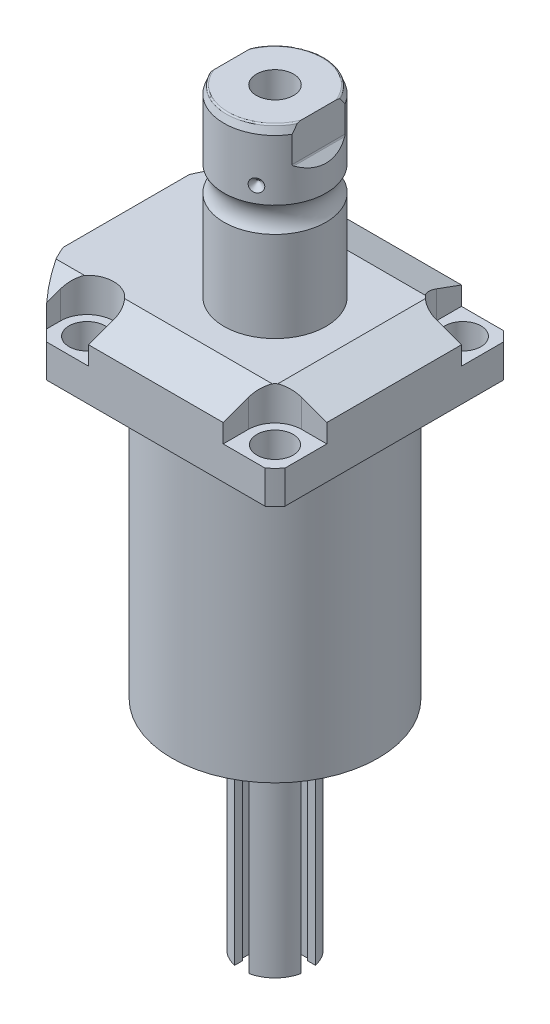
from build123d import *

# Parameters (mm, degrees)
SKETCH1_W                   = 88.9
SKETCH1_H                   = 99.9998
EXTRUDE1_DEPTH              = 129.794
SKETCH2_OUTSIDE_W           = 139.282
SKETCH2_OUTSIDE_H           = 128.182
SKETCH2_OUTSIDE_R           = 60.325
CUT_EXTRUDE1_DEPTH          = 130.794
SKETCH3_W                   = 38.1
SKETCH3_H                   = 104.775
FILLET1_R                   = 0.381
CUT_EXTRUDE2_DEPTH          = 12.7
CUT_EXTRUDE9_START          = -56.5498
CUT_EXTRUDE9_DEPTH          = 101.9998
CUT_EXTRUDE7_DEPTH          = 45.45
CUT_EXTRUDE7_DEPTH_BACK     = 45.45
SKETCH10_R                  = 1.1811
SKETCH11_R                  = 1.1811
CUT_EXTRUDE8_DEPTH          = 53.34
SKETCH17_W                  = 6.7437
SKETCH17_H                  = 12.319
HOLE1_AT_2_COUNT            = 2
HOLE1_AT_2_PITCH            = 70.104
HOLE1_AT_3_COUNT            = 2
HOLE1_AT_3_PITCH            = 99.142027577
HOLE1_AT_4_COUNT            = 2
HOLE1_AT_4_PITCH            = 70.104
CHAMFER1_SIZE               = 0.635
FILLET2_R                   = 0.635
CIRPATTERN1_COUNT           = 3
SKETCH24_R                  = 1.7272
CUT_EXTRUDE10_DEPTH         = 2.54
SKETCH25_R                  = 2.7051
EXTRUDE2_DEPTH              = 2.9464
CUT_EXTRUDE11_DEPTH         = 6.477
SKETCH32_W                  = 6.985
SKETCH32_H                  = 70.612
CUT_EXTRUDE12_DEPTH         = 3.302
CUT_EXTRUDE13_DEPTH         = 2.032
CIRPATTERN2_COUNT           = 2
CIRPATTERN2_ANGLE           = 90
CIRPATTERN2_COPY_1_DEPTH    = 6.477
CIRPATTERN2_COPY_2_SKETCH_W = 6.985
CIRPATTERN2_COPY_2_SKETCH_H = 70.612
CIRPATTERN2_COPY_2_DEPTH    = 3.302


with BuildPart() as part:
    # Sketch1 → Extrude1 (new body)
    with BuildSketch(Plane.ZX):
        with Locations((0, -5.5499)):
            Rectangle(SKETCH1_W, SKETCH1_H)
    extrude(amount=EXTRUDE1_DEPTH)

    # Sketch2 outside → Cut-Extrude1 (cut, through all)
    with BuildSketch(Plane.XZ):
        with Locations((-5.55, 0)):
            Rectangle(SKETCH2_OUTSIDE_W, SKETCH2_OUTSIDE_H)
        Circle(SKETCH2_OUTSIDE_R, mode=Mode.SUBTRACT)
    extrude(amount=-CUT_EXTRUDE1_DEPTH, mode=Mode.SUBTRACT)

    # Sketch3 → Cut-Revolve1 (revolve, cut)
    with BuildSketch(Plane(origin=(0, 0, 0), x_dir=(0, 0, 1), z_dir=(1, 0, 0))):
        with Locations((57.5437, -52.3875)):
            Rectangle(SKETCH3_W, SKETCH3_H)
    revolve(axis=Axis((0, 93.345, 0), (0, -1, 0)), mode=Mode.SUBTRACT)

    # Fillet1
    fillet1_edges = [part.edges().sort_by_distance(p)[0] for p in [
        (0, 104.775, -38.4937),
    ]]
    fillet(fillet1_edges, radius=FILLET1_R)

    # Sketch4 → Cut-Extrude2 (cut)
    with BuildSketch(Plane(origin=(0, 129.794, 0), x_dir=(-1, 0, 0), z_dir=(0, 1, 0))):
        with BuildLine():
            Line((-25.1206, -44.45), (-25.1206, -35.052))
            ThreePointArc((-25.1206, -35.052), (-28.029439713, -28.029439713), (-35.052, -25.1206))
            Line((-35.052, -25.1206), (-44.45, -25.1206))
            Line((-44.45, -25.1206), (-44.45, -44.45))
            Line((-44.45, -44.45), (-25.1206, -44.45))
        make_face()
        with BuildLine():
            Line((44.9834, -44.45), (25.1206, -44.45))
            Line((25.1206, -44.45), (25.1206, -35.052))
            ThreePointArc((25.1206, -35.052), (35.052, -25.1206), (44.9834, -35.052))
            Line((44.9834, -35.052), (44.9834, -44.45))
        make_face()
        with BuildLine():
            Line((25.1206, 44.45), (25.1206, 35.052))
            ThreePointArc((25.1206, 35.052), (35.052, 25.1206), (44.9834, 35.052))
            Line((44.9834, 35.052), (44.9834, 44.45))
            Line((44.9834, 44.45), (25.1206, 44.45))
        make_face()
        with BuildLine():
            Line((-35.052, 25.1206), (-44.45, 25.1206))
            Line((-44.45, 25.1206), (-44.45, 44.45))
            Line((-44.45, 44.45), (-25.1206, 44.45))
            Line((-25.1206, 44.45), (-25.1206, 35.052))
            ThreePointArc((-25.1206, 35.052), (-28.029439713, 28.029439713), (-35.052, 25.1206))
        make_face()
    extrude(amount=-CUT_EXTRUDE2_DEPTH, mode=Mode.SUBTRACT)

    # Sketch5 → Cut-Extrude9 (cut)
    with BuildSketch(Plane(origin=(0, 0, 0), x_dir=(0, 0, -1), z_dir=(1, 0, 0)).offset(CUT_EXTRUDE9_START)):
        Polygon((-28.575, 129.794), (-44.45, 124.015972531), (-44.45, 129.794), align=None)
    cut_extrude9 = extrude(amount=CUT_EXTRUDE9_DEPTH, mode=Mode.SUBTRACT)

    # Mirror1: Cut-Extrude9 across plane
    add(cut_extrude9.mirror(Plane.XY), mode=Mode.SUBTRACT)

    # Sketch9 → Cut-Extrude7 (cut, two sides)
    with BuildSketch(Plane.XY) as cut_extrude7_sk:
        Polygon((28.575, 129.794), (44.45, 124.015972531), (44.45, 129.794), align=None)
    extrude(amount=CUT_EXTRUDE7_DEPTH, mode=Mode.SUBTRACT)
    extrude(cut_extrude7_sk.sketch, amount=-CUT_EXTRUDE7_DEPTH_BACK, mode=Mode.SUBTRACT)

    # Sketch20 → Cut-Revolve4 (revolve, cut)
    with BuildSketch(Plane(origin=(-41.402, 88.9, -18.1102), x_dir=(0, 1, 0), z_dir=(1, 0, 0)), mode=Mode.PRIVATE) as cut_revolve4_sk:
        Polygon((15.875, 41.9227), (17.3228, 41.9227), (17.3228, 39.4716), (18.3388, 39.4716), (18.3388, 37.465), (29.3116, 37.465), (29.3116, 36.2204), (15.875, 36.2204), align=None)
    cut_revolve4 = revolve(cut_revolve4_sk.sketch.rotate(Axis((-41.402, 81.620304954, 18.1102), (0, 1, 0)), 180), axis=Axis((-41.402, 81.620304954, 18.1102), (0, 1, 0)), mode=Mode.SUBTRACT)  # turned: the seam where the file's is

    # Mirror10: Cut-Revolve4 across plane
    add(cut_revolve4.mirror(Plane.XY), mode=Mode.SUBTRACT)

    # S2D0007 → Cut-Revolve2 (revolve, cut)
    with BuildSketch(Plane(origin=(-55.5498, 101.9048, 12.9794), x_dir=(0, 1, 0), z_dir=(0, 0, 1)), mode=Mode.PRIVATE) as cut_revolve2_sk:
        Polygon((15.875, 0), (26.3525, 0), (26.3525, -0.254), (22.0599, -0.254), (21.517306865, -2.8067), (20.8534, -3.470606865), (20.8534, -14.224), (15.875, -14.224), align=None)
    revolve(cut_revolve2_sk.sketch.rotate(Axis((944.4502, 117.7798, 12.9794), (-1, 0, 0)), 90), axis=Axis((944.4502, 117.7798, 12.9794), (-1, 0, 0)), mode=Mode.SUBTRACT)  # turned: the seam where the file's is

    # Sketch13 → Cut-Revolve3 (revolve, cut)
    with BuildSketch(Plane(origin=(-55.5498, 101.9048, -12.9794), x_dir=(0, 1, 0), z_dir=(0, 0, 1)), mode=Mode.PRIVATE) as cut_revolve3_sk:
        Polygon((15.875, 0), (26.3525, 0), (26.3525, -0.254), (22.0599, -0.254), (21.517306865, -2.8067), (20.8534, -3.470606865), (20.8534, -14.224), (15.875, -14.224), align=None)
    revolve(cut_revolve3_sk.sketch.rotate(Axis((944.4502, 117.7798, -12.9794), (-1, 0, 0)), 90), axis=Axis((944.4502, 117.7798, -12.9794), (-1, 0, 0)), mode=Mode.SUBTRACT)  # turned: the seam where the file's is

    # Sketch15 → Revolve3 (revolve)
    with BuildSketch(Plane(origin=(0, 0, 0), x_dir=(0, -1, 0), z_dir=(1, 0, 0)), mode=Mode.PRIVATE) as revolve3_sk:
        with BuildLine():
            Line((-129.794, 0), (-129.794, 19.05))
            Line((-129.794, 19.05), (-163.46630643, 19.05))
            ThreePointArc((-163.46630643, 19.05), (-168.1734, 17.5006), (-172.88049357, 19.05))
            Line((-172.88049357, 19.05), (-195.4276, 19.05))
            Line((-195.4276, 19.05), (-198.3486, 17.986842946))
            Line((-198.3486, 17.986842946), (-198.3486, 0))
            Line((-198.3486, 0), (-129.794, 0))
        make_face()
    revolve(revolve3_sk.sketch.rotate(Axis((0, 197.63613, 0), (0, -1, 0)), 180), axis=Axis((0, 197.63613, 0), (0, -1, 0)))  # turned: the seam where the file's is

    # Sketch16 → Cut-Extrude8 (cut, symmetric)
    with BuildSketch(Plane(origin=(0, 0, 0), x_dir=(0, -1, 0), z_dir=(0, 0, -1))):
        with BuildLine():
            Line((-198.3486, 19.05), (-182.564369265, 19.05))
            Line((-182.564369265, 19.05), (-185.109784633, 16.504584633))
            ThreePointArc((-185.109784633, 16.504584633), (-185.356995225, 16.339403796), (-185.6486, 16.2814))
            Line((-185.6486, 16.2814), (-198.3486, 16.2814))
            Line((-198.3486, 16.2814), (-198.3486, 19.05))
        make_face()
        with BuildLine():
            Line((-198.3486, -19.05), (-198.3486, -16.2814))
            Line((-198.3486, -16.2814), (-185.6486, -16.2814))
            ThreePointArc((-185.6486, -16.2814), (-185.356995225, -16.339403796), (-185.109784633, -16.504584633))
            Line((-185.109784633, -16.504584633), (-182.564369265, -19.05))
            Line((-182.564369265, -19.05), (-198.3486, -19.05))
        make_face()
    extrude(amount=CUT_EXTRUDE8_DEPTH, both=True, mode=Mode.SUBTRACT)

    # Sketch17 → Hole1 (revolve, cut)
    with BuildSketch(Plane(origin=(35.052, 117.094, -35.052), x_dir=(0, 0, 1), z_dir=(1, 0, 0))):
        with Locations((3.37185, 6.1595)):
            Rectangle(SKETCH17_W, SKETCH17_H)
    hole1 = revolve(axis=Axis((35.052, 7.094, -35.052), (0, 1, 0)), mode=Mode.SUBTRACT)

    # Hole1 at 2: Hole1 ×2
    with Locations(*[(0, 0, i * HOLE1_AT_2_PITCH) for i in range(1, HOLE1_AT_2_COUNT)]):
        add(hole1, mode=Mode.SUBTRACT)

    # Hole1 at 3: Hole1 ×2
    with Locations(*[Vector(-0.707106781, 0, 0.707106781) * (i * HOLE1_AT_3_PITCH) for i in range(1, HOLE1_AT_3_COUNT)]):
        add(hole1, mode=Mode.SUBTRACT)

    # Hole1 at 4: Hole1 ×2
    with Locations(*[(-i * HOLE1_AT_4_PITCH, 0, 0) for i in range(1, HOLE1_AT_4_COUNT)]):
        add(hole1, mode=Mode.SUBTRACT)

    # Chamfer1
    chamfer1_edges = [part.edges().sort_by_distance(p)[0] for p in [
        (-41.402, 107.2388, 19.3548),
        (-41.402, 107.2388, -19.3548),
    ]]
    chamfer(chamfer1_edges, length=CHAMFER1_SIZE)

    # Sketch21 → Cut-Revolve5 (revolve, cut)
    with BuildSketch(Plane.XY, mode=Mode.PRIVATE) as cut_revolve5_sk:
        Polygon((0, 172.9486), (6.9342, 177.115087704), (6.9342, 198.3486), (0, 198.3486), align=None)
    revolve(cut_revolve5_sk.sketch.rotate(Axis((0, 0, 0), (0, 1, 0)), 270), axis=Axis((0, 0, 0), (0, 1, 0)), mode=Mode.SUBTRACT)  # turned: the seam where the file's is

    # Fillet2
    fillet2_edges = [part.edges().sort_by_distance(p)[0] for p in [
        (0, 198.3486, 17.986842946),
        (0, 198.3486, -17.986842946),
    ]]
    fillet(fillet2_edges, radius=FILLET2_R)

    # Sketch22 → Cut-Revolve6 (revolve, cut)
    with BuildSketch(Plane.XY, mode=Mode.PRIVATE) as cut_revolve6_sk:
        Polygon((-19.05, 181.2544), (-16.637, 178.8414), (-19.05, 178.8414), align=None)
    cut_revolve6 = revolve(cut_revolve6_sk.sketch.rotate(Axis((-37.997376206, 178.8414, 0), (1, 0, 0)), 90), axis=Axis((-37.997376206, 178.8414, 0), (1, 0, 0)), mode=Mode.SUBTRACT)  # turned: the seam where the file's is

    # CirPattern1: Cut-Revolve6 ×3 about axis
    cirpattern1_axis = Axis((0, 197.63613, 0), (0, 1, 0))
    for i in range(1, CIRPATTERN1_COUNT):
        add(cut_revolve6.rotate(cirpattern1_axis, i * 360 / CIRPATTERN1_COUNT), mode=Mode.SUBTRACT)

    # Sketch23 → Revolve5 (revolve)
    with BuildSketch(Plane.XY, mode=Mode.PRIVATE) as revolve5_sk:
        Polygon((0, 0), (22.225, 0), (22.225, -2.54), (12.7, -2.54), (12.7, -81.28), (0, -81.28), align=None)
    revolve(revolve5_sk.sketch.rotate(Axis((0, -1000, 0), (0, 1, 0)), 270), axis=Axis((0, -1000, 0), (0, 1, 0)))  # turned: the seam where the file's is

    # Sketch24 → Cut-Extrude10 (cut)
    with BuildSketch(Plane.XZ.offset(2.54)):
        with Locations((19.431, 0)):
            Circle(SKETCH24_R)
        with Locations((16.827739621, 9.7155)):
            Circle(SKETCH24_R)
        with Locations((9.7155, 16.827739621)):
            Circle(SKETCH24_R)
        with Locations((0, 19.431)):
            Circle(SKETCH24_R)
        with Locations(Location((-9.7155, 16.827739621, 0), (0, 0, 270))):  # turned: the seam where the file's is
            Circle(SKETCH24_R)
        with Locations(Location((-16.827739621, 9.7155, 0), (0, 0, 270))):  # turned: the seam where the file's is
            Circle(SKETCH24_R)
        with Locations(Location((-19.431, 0, 0), (0, 0, 270))):  # turned: the seam where the file's is
            Circle(SKETCH24_R)
        with Locations((-16.827739621, -9.7155)):
            Circle(SKETCH24_R)
        with Locations((-9.7155, -16.827739621)):
            Circle(SKETCH24_R)
        with Locations(Location((0, -19.431, 0), (0, 0, 270))):  # turned: the seam where the file's is
            Circle(SKETCH24_R)
        with Locations(Location((9.7155, -16.827739621, 0), (0, 0, 270))):  # turned: the seam where the file's is
            Circle(SKETCH24_R)
        with Locations(Location((16.827739621, -9.7155, 0), (0, 0, 270))):  # turned: the seam where the file's is
            Circle(SKETCH24_R)
    extrude(amount=-CUT_EXTRUDE10_DEPTH, mode=Mode.SUBTRACT)

    # Sketch25 → Extrude2 (add)
    with BuildSketch(Plane.XZ.offset(2.54)):
        with Locations((19.431, 0)):
            Circle(SKETCH25_R)
        with Locations((-9.7155, 16.827739621)):
            Circle(SKETCH25_R)
        with Locations((-9.7155, -16.827739621)):
            Circle(SKETCH25_R)
    extrude(amount=EXTRUDE2_DEPTH)

    # Sketch31 → Cut-Extrude11 (cut)
    with BuildSketch(Plane(origin=(0, -41.91, 12.7), x_dir=(-1, 0, 0), z_dir=(0, 0, 1))):
        with BuildLine():
            Line((-2.6416, -28.957376248), (-2.6416, 39.37))
            Line((-2.6416, 39.37), (2.6416, 39.37))
            Line((2.6416, 39.37), (2.6416, -28.957376248))
            ThreePointArc((2.6416, -28.957376248), (0, -34.7345), (-2.6416, -28.957376248))
        make_face()
    cut_extrude11 = extrude(amount=-CUT_EXTRUDE11_DEPTH, mode=Mode.SUBTRACT)

    # Sketch32 → Cut-Extrude12 (cut)
    with BuildSketch(Plane.XY.offset(6.223)):
        with Locations((0, -45.974)):
            Rectangle(SKETCH32_W, SKETCH32_H)
    cut_extrude12 = extrude(amount=CUT_EXTRUDE12_DEPTH, mode=Mode.SUBTRACT)

    # Mirror11: Cut-Extrude11, Cut-Extrude12 across plane
    add(cut_extrude11.mirror(Plane.XY), mode=Mode.SUBTRACT)
    add(cut_extrude12.mirror(Plane.XY), mode=Mode.SUBTRACT)

    # Sketch35 → Cut-Extrude13 (cut)
    with BuildSketch(Plane.XZ.offset(5.4864)):
        Polygon((19.431, -1.43714029), (20.6756, -0.718570145), (20.6756, 0.718570145), (19.431, 1.43714029), (18.1864, 0.718570145), (18.1864, -0.718570145), align=None)
        Polygon((-9.255302101, 15.46627346), (-8.306336769, 16.545549612), (-8.766534668, 17.907015772), (-10.175697899, 18.189205782), (-11.124663231, 17.10992963), (-10.664465332, 15.748463469), align=None)
        Polygon((-9.7155, -18.264879911), (-8.4709, -17.546309766), (-8.4709, -16.109169476), (-9.7155, -15.390599331), (-10.9601, -16.109169476), (-10.9601, -17.546309766), align=None)
    extrude(amount=-CUT_EXTRUDE13_DEPTH, mode=Mode.SUBTRACT)

    # CirPattern2: Cut-Extrude11, Cut-Extrude12 ×2 about axis
    cirpattern2_axis = Axis((0, 0, 0), (0, -1, 0))
    add([cut_extrude11.rotate(cirpattern2_axis, i * CIRPATTERN2_ANGLE / (CIRPATTERN2_COUNT - 1)) for i in range(1, CIRPATTERN2_COUNT)], mode=Mode.SUBTRACT)
    add([cut_extrude12.rotate(cirpattern2_axis, i * CIRPATTERN2_ANGLE / (CIRPATTERN2_COUNT - 1)) for i in range(1, CIRPATTERN2_COUNT)], mode=Mode.SUBTRACT)

    # CirPattern2 copy 1 sketch → CirPattern2 copy 1 (cut)
    with BuildSketch(Plane(origin=(12.7, -41.91, 0), x_dir=(0, 0, -1), z_dir=(1, 0, 0))):
        with BuildLine():
            Line((-2.6416, 28.957376248), (-2.6416, -39.37))
            Line((-2.6416, -39.37), (2.6416, -39.37))
            Line((2.6416, -39.37), (2.6416, 28.957376248))
            ThreePointArc((2.6416, 28.957376248), (0, 34.7345), (-2.6416, 28.957376248))
        make_face()
    extrude(amount=-CIRPATTERN2_COPY_1_DEPTH, mode=Mode.SUBTRACT)

    # CirPattern2 copy 2 sketch → CirPattern2 copy 2 (cut)
    with BuildSketch(Plane(origin=(6.223, 0, 0), x_dir=(0, 0, 1), z_dir=(1, 0, 0))):
        with Locations((0, 45.974)):
            Rectangle(CIRPATTERN2_COPY_2_SKETCH_W, CIRPATTERN2_COPY_2_SKETCH_H)
    extrude(amount=CIRPATTERN2_COPY_2_DEPTH, mode=Mode.SUBTRACT)


with BuildPart() as body_2:
    # Sketch10 → Revolve4 (revolve)
    with BuildSketch(Plane(origin=(-41.402, 88.9, -18.1102), x_dir=(0, 1, 0), z_dir=(1, 0, 0))):
        with Locations((16.1417, 4.5212)):
            Circle(SKETCH10_R)
    revolve(axis=Axis((-41.402, 87.86749, -18.1102), (0, 1, 0)))


with BuildPart() as body_3:
    # Sketch11 → Revolve2 (revolve)
    with BuildSketch(Plane(origin=(-41.402, 88.9, 18.1102), x_dir=(0, 1, 0), z_dir=(1, 0, 0)), mode=Mode.PRIVATE) as revolve2_sk:
        with Locations((16.1417, 4.5212)):
            Circle(SKETCH11_R)
    revolve(revolve2_sk.sketch.rotate(Axis((-41.402, 87.86749, 18.1102), (0, 1, 0)), 180), axis=Axis((-41.402, 87.86749, 18.1102), (0, 1, 0)))  # turned: the seam where the file's is


solid = Compound([part.part, body_2.part, body_3.part])
